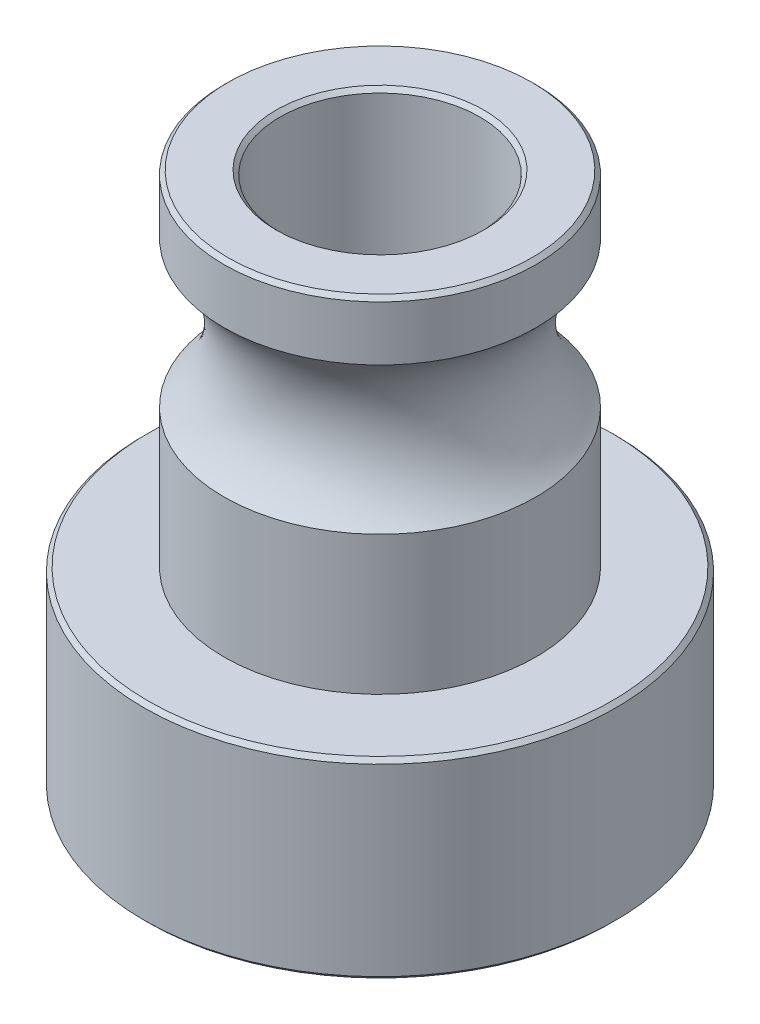
from build123d import *

# Parameters (mm, degrees)
CROQUIS1_R              = 5.9
SALIENTE_EXTRUIR1_DEPTH = 4.8
CROQUIS2_R              = 3.9
SALIENTE_EXTRUIR2_DEPTH = 13.4
CROQUIS3_R              = 2.5
CORTAR_EXTRUIR1_DEPTH   = 14.4
CHAFL_N1_SIZE           = 0.1
CROQUIS4_R              = 2.5
CROQUIS5_R              = 1.5
CORTAR_EXTRUIR2_DEPTH   = 6.9


with BuildPart() as part:
    # Croquis1 → Saliente-Extruir1 (new body)
    with BuildSketch(Plane(origin=(0, 0, 0), x_dir=(1, 0, 0), z_dir=(0, 1, 0))):
        Circle(CROQUIS1_R)
    extrude(amount=SALIENTE_EXTRUIR1_DEPTH)

    # Croquis2 → Saliente-Extruir2 (add)
    with BuildSketch(Plane(origin=(0, 0, 0), x_dir=(1, 0, 0), z_dir=(0, 1, 0))):
        Circle(CROQUIS2_R)
    extrude(amount=SALIENTE_EXTRUIR2_DEPTH)

    # Croquis3 → Cortar-Extruir1 (cut, through all)
    with BuildSketch(Plane(origin=(0, 13.4, 0), x_dir=(1, 0, 0), z_dir=(0, 1, 0))):
        Circle(CROQUIS3_R)
    extrude(amount=-CORTAR_EXTRUIR1_DEPTH, mode=Mode.SUBTRACT)

    # Chaflán1
    chafl_n1_edges = [part.edges().sort_by_distance(p)[0] for p in [
        (-2.5, 0, 0),
        (-2.5, 13.4, 0),
        (-5.9, 0, 0),
        (-5.9, 4.8, 0),
        (-3.9, 13.4, 0),
    ]]
    chamfer(chafl_n1_edges, length=CHAFL_N1_SIZE)

    # Croquis4 → Cortar-Revolución2 (revolve, cut)
    with BuildSketch(Plane(origin=(0, 0, 0), x_dir=(0, 0, -1), z_dir=(1, 0, 0))):
        with Locations((-5.6, 10.1)):
            Circle(CROQUIS4_R)
    revolve(axis=Axis((0, 13.979474026, 0), (0, -1, 0)), mode=Mode.SUBTRACT)

    # Croquis5 → Cortar-Extruir2 (cut, through all)
    with BuildSketch(Plane.XY):
        with Locations((0, 2.4)):
            Circle(CROQUIS5_R)
    extrude(amount=-CORTAR_EXTRUIR2_DEPTH, mode=Mode.SUBTRACT)


solid = part.part
